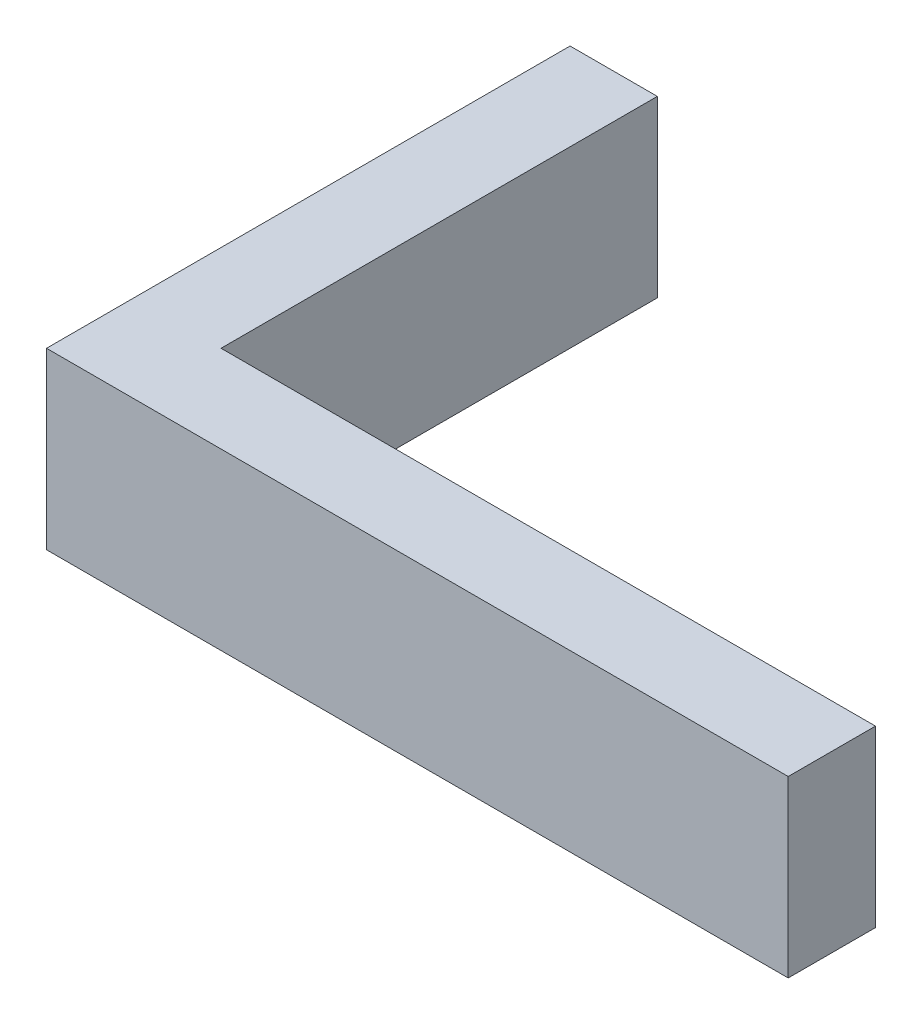
from build123d import *

# Parameters (mm, degrees)
BOSS_EXTRUDE1_DEPTH = 4


with BuildPart() as part:
    # Sketch2 → Boss-Extrude1 (new body)
    with BuildSketch(Plane(origin=(0, 0, 0), x_dir=(1, 0, 0), z_dir=(0, 1, 0))):
        Polygon((-12.731707317, 5), (-12.731707317, -7), (4.268292683, -7), (4.268292683, -5), (-10.731707317, -5), (-10.731707317, 5), align=None)
    extrude(amount=BOSS_EXTRUDE1_DEPTH)


solid = part.part
